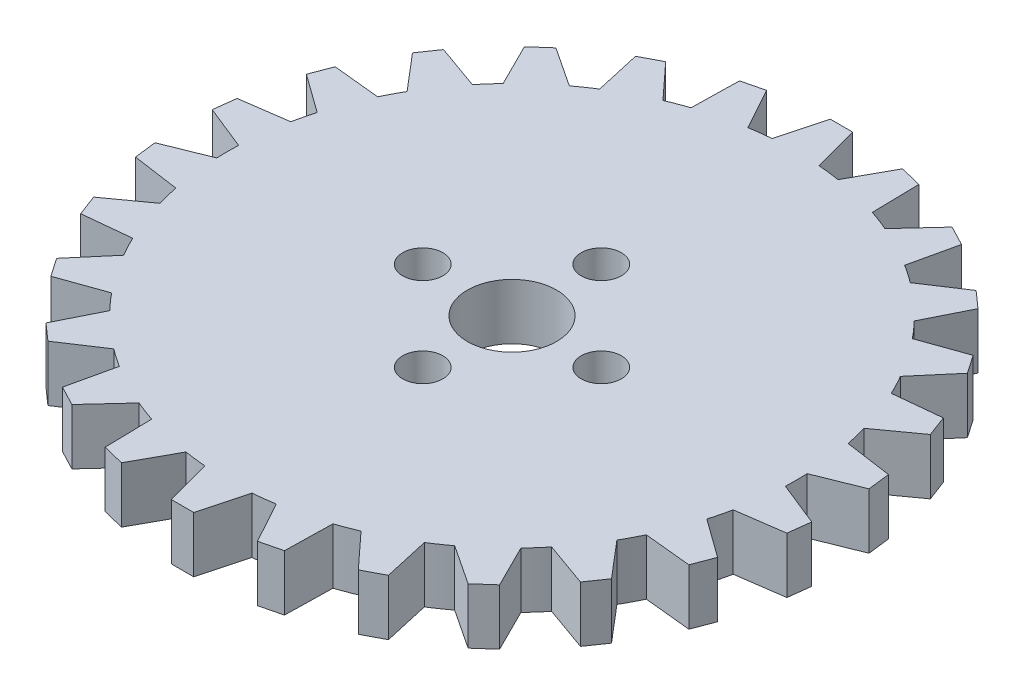
from build123d import *

# Parameters (mm, degrees)
BOSS_EXTRUDE1_DEPTH = 3.175
SKETCH2_R           = 1.143
SKETCH2_R_2         = 2.54
CUT_EXTRUDE1_DEPTH  = 3.175


with BuildPart() as part:
    # Sketch1 → Boss-Extrude1 (new body)
    with BuildSketch(Plane(origin=(0, 0, 0), x_dir=(1, 0, 0), z_dir=(0, 1, 0))):
        with BuildLine():
            Line((0.635, 18.750209072), (-0.635, 18.750209114))
            Line((-0.635, 18.750209114), (-1.33510965, 16.137364669))
            ThreePointArc((-1.33510965, 16.137364669), (-1.951790294, 16.074438432), (-2.565610552, 15.987954802))
            Line((-2.565610552, 15.987954802), (-3.870670686, 18.357327521))
            Line((-3.870670686, 18.357327521), (-5.103766804, 18.053396667))
            Line((-5.103766804, 18.053396667), (-5.158237936, 15.348929528))
            ThreePointArc((-5.158237936, 15.348929528), (-5.741939727, 15.140250474), (-6.317226596, 14.909383099))
            Line((-6.317226596, 14.909383099), (-8.15139206, 16.897584819))
            Line((-8.15139206, 16.897584819), (-9.275921232, 16.307386428))
            Line((-9.275921232, 16.307386428), (-8.681588182, 13.668470393))
            ThreePointArc((-8.681588182, 13.668470393), (-9.198388493, 13.326166192), (-9.701708393, 12.964332243))
            Line((-9.701708393, 12.964332243), (-11.958384157, 14.455815909))
            Line((-11.958384157, 14.455815909), (-12.908992835, 13.613650164))
            Line((-12.908992835, 13.613650164), (-11.70039608, 11.193649442))
            ThreePointArc((-11.70039608, 11.193649442), (-12.120260356, 10.737613569), (-12.522362162, 10.265841521))
            Line((-12.522362162, 10.265841521), (-15.070398434, 11.173927523))
            Line((-15.070398434, 11.173927523), (-15.791840697, 10.128738036))
            Line((-15.791840697, 10.128738036), (-14.039219486, 8.068294272))
            ThreePointArc((-14.039219486, 8.068294272), (-14.337746742, 7.525029875), (-14.615261759, 6.970737405))
            Line((-14.615261759, 6.970737405), (-17.306575933, 7.242651084))
            Line((-17.306575933, 7.242651084), (-17.756924178, 6.055180471))
            Line((-17.756924178, 6.055180471), (-15.562134487, 4.474039167))
            ThreePointArc((-15.562134487, 4.474039167), (-15.721975403, 3.875118797), (-15.858775467, 3.270519368))
            Line((-15.858775467, 3.270519368), (-18.536958145, 2.890458091))
            Line((-18.536958145, 2.890458091), (-18.69003977, 1.629717826))
            Line((-18.69003977, 1.629717826), (-16.180634797, 0.619769168))
            ThreePointArc((-16.180634797, 0.619769168), (-16.1925, -1e-07), (-16.180634789, -0.619769367))
            Line((-16.180634789, -0.619769367), (-18.690039729, -1.629717821))
            Line((-18.690039729, -1.629717821), (-18.536958186, -2.890458096))
            Line((-18.536958186, -2.890458096), (-15.858775427, -3.270519563))
            ThreePointArc((-15.858775427, -3.270519563), (-15.721975355, -3.875118991), (-15.562134432, -4.474039358))
            Line((-15.562134432, -4.474039358), (-17.75692414, -6.055180456))
            Line((-17.75692414, -6.055180456), (-17.306575972, -7.242651099))
            Line((-17.306575972, -7.242651099), (-14.615261673, -6.970737585))
            ThreePointArc((-14.615261673, -6.970737585), (-14.337746649, -7.525030051), (-14.039219387, -8.068294445))
            Line((-14.039219387, -8.068294445), (-15.791840663, -10.128738013))
            Line((-15.791840663, -10.128738013), (-15.070398469, -11.173927546))
            Line((-15.070398469, -11.173927546), (-12.522362036, -10.265841675))
            ThreePointArc((-12.522362036, -10.265841675), (-12.120260224, -10.737613718), (-11.700395942, -11.193649586))
            Line((-11.700395942, -11.193649586), (-12.908992808, -13.613650133))
            Line((-12.908992808, -13.613650133), (-11.958384185, -14.45581594))
            Line((-11.958384185, -14.45581594), (-9.701708233, -12.964332363))
            ThreePointArc((-9.701708233, -12.964332363), (-9.198388329, -13.326166305), (-8.681588014, -13.6684705))
            Line((-8.681588014, -13.6684705), (-9.275921213, -16.307386391))
            Line((-9.275921213, -16.307386391), (-8.15139208, -16.897584856))
            Line((-8.15139208, -16.897584856), (-6.317226413, -14.909383176))
            ThreePointArc((-6.317226413, -14.909383176), (-5.74193954, -15.140250545), (-5.158237747, -15.348929591))
            Line((-5.158237747, -15.348929591), (-5.103766794, -18.053396627))
            Line((-5.103766794, -18.053396627), (-3.870670696, -18.357327561))
            Line((-3.870670696, -18.357327561), (-2.565610355, -15.987954833))
            ThreePointArc((-2.565610355, -15.987954833), (-1.951790096, -16.074438456), (-1.335109452, -16.137364686))
            Line((-1.335109452, -16.137364686), (-0.635, -18.750209072))
            Line((-0.635, -18.750209072), (0.635, -18.750209114))
            Line((0.635, -18.750209114), (1.33510965, -16.137364669))
            ThreePointArc((1.33510965, -16.137364669), (1.951790294, -16.074438432), (2.565610552, -15.987954802))
            Line((2.565610552, -15.987954802), (3.870670686, -18.357327521))
            Line((3.870670686, -18.357327521), (5.103766804, -18.053396667))
            Line((5.103766804, -18.053396667), (5.158237936, -15.348929528))
            ThreePointArc((5.158237936, -15.348929528), (5.741939727, -15.140250474), (6.317226596, -14.909383099))
            Line((6.317226596, -14.909383099), (8.15139206, -16.897584819))
            Line((8.15139206, -16.897584819), (9.275921232, -16.307386428))
            Line((9.275921232, -16.307386428), (8.681588182, -13.668470393))
            ThreePointArc((8.681588182, -13.668470393), (9.198388493, -13.326166192), (9.701708393, -12.964332243))
            Line((9.701708393, -12.964332243), (11.958384157, -14.455815909))
            Line((11.958384157, -14.455815909), (12.908992835, -13.613650164))
            Line((12.908992835, -13.613650164), (11.70039608, -11.193649442))
            ThreePointArc((11.70039608, -11.193649442), (12.120260356, -10.737613569), (12.522362162, -10.265841521))
            Line((12.522362162, -10.265841521), (15.070398434, -11.173927523))
            Line((15.070398434, -11.173927523), (15.791840697, -10.128738036))
            Line((15.791840697, -10.128738036), (14.039219486, -8.068294272))
            ThreePointArc((14.039219486, -8.068294272), (14.337746742, -7.525029875), (14.615261759, -6.970737405))
            Line((14.615261759, -6.970737405), (17.306575933, -7.242651084))
            Line((17.306575933, -7.242651084), (17.756924178, -6.055180471))
            Line((17.756924178, -6.055180471), (15.562134487, -4.474039167))
            ThreePointArc((15.562134487, -4.474039167), (15.721975403, -3.875118797), (15.858775467, -3.270519368))
            Line((15.858775467, -3.270519368), (18.536958145, -2.890458091))
            Line((18.536958145, -2.890458091), (18.69003977, -1.629717826))
            Line((18.69003977, -1.629717826), (16.180634797, -0.619769168))
            ThreePointArc((16.180634797, -0.619769168), (16.1925, 1e-07), (16.180634789, 0.619769367))
            Line((16.180634789, 0.619769367), (18.690039729, 1.629717821))
            Line((18.690039729, 1.629717821), (18.536958186, 2.890458096))
            Line((18.536958186, 2.890458096), (15.858775427, 3.270519563))
            ThreePointArc((15.858775427, 3.270519563), (15.721975355, 3.875118991), (15.562134432, 4.474039358))
            Line((15.562134432, 4.474039358), (17.75692414, 6.055180456))
            Line((17.75692414, 6.055180456), (17.306575972, 7.242651099))
            Line((17.306575972, 7.242651099), (14.615261673, 6.970737585))
            ThreePointArc((14.615261673, 6.970737585), (14.337746649, 7.525030051), (14.039219387, 8.068294445))
            Line((14.039219387, 8.068294445), (15.791840663, 10.128738013))
            Line((15.791840663, 10.128738013), (15.070398469, 11.173927546))
            Line((15.070398469, 11.173927546), (12.522362036, 10.265841675))
            ThreePointArc((12.522362036, 10.265841675), (12.120260224, 10.737613718), (11.700395942, 11.193649586))
            Line((11.700395942, 11.193649586), (12.908992808, 13.613650133))
            Line((12.908992808, 13.613650133), (11.958384185, 14.45581594))
            Line((11.958384185, 14.45581594), (9.701708233, 12.964332363))
            ThreePointArc((9.701708233, 12.964332363), (9.198388329, 13.326166305), (8.681588014, 13.6684705))
            Line((8.681588014, 13.6684705), (9.275921213, 16.307386391))
            Line((9.275921213, 16.307386391), (8.15139208, 16.897584856))
            Line((8.15139208, 16.897584856), (6.317226413, 14.909383176))
            ThreePointArc((6.317226413, 14.909383176), (5.74193954, 15.140250545), (5.158237747, 15.348929591))
            Line((5.158237747, 15.348929591), (5.103766794, 18.053396627))
            Line((5.103766794, 18.053396627), (3.870670696, 18.357327561))
            Line((3.870670696, 18.357327561), (2.565610355, 15.987954833))
            ThreePointArc((2.565610355, 15.987954833), (1.951790096, 16.074438456), (1.335109452, 16.137364686))
            Line((1.335109452, 16.137364686), (0.635, 18.750209072))
        make_face()
    extrude(amount=BOSS_EXTRUDE1_DEPTH)

    # Sketch2 → Cut-Extrude1 (cut)
    with BuildSketch(Plane(origin=(0, 0, 0), x_dir=(1, 0, 0), z_dir=(0, 1, 0))):
        with Locations((-5.08, 0)):
            Circle(SKETCH2_R)
        with Locations((0, 5.08)):
            Circle(SKETCH2_R)
        with Locations((5.08, 0)):
            Circle(SKETCH2_R)
        with Locations((0, -5.08)):
            Circle(SKETCH2_R)
        Circle(SKETCH2_R_2)
    extrude(amount=CUT_EXTRUDE1_DEPTH, mode=Mode.SUBTRACT)


solid = part.part
